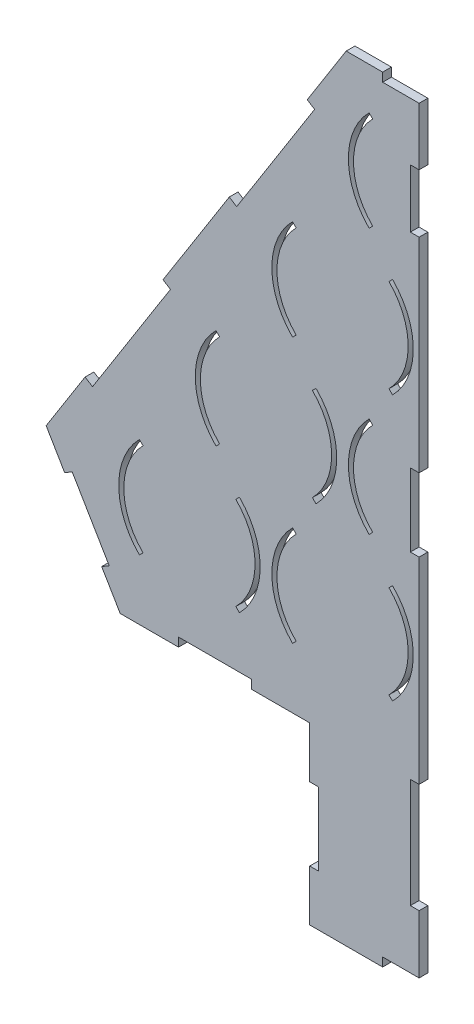
from build123d import *

# Parameters (mm, degrees)
BOSS_EXTRU_1_DEPTH      = 6
ESQUISSE2_W             = 150
ESQUISSE2_H             = 120
BOSS_EXTRU_2_DEPTH      = 6
ESQUISSE3_W             = 6
ESQUISSE3_H             = 50
ESQUISSE3_W_2           = 50
ESQUISSE3_H_2           = 6
ENL_V_MAT_EXTRU_1_DEPTH = 10
ESQUISSE4_W             = 50
ESQUISSE4_H             = 6
ENL_V_MAT_EXTRU_2_DEPTH = 10
ESQUISSE5_W             = 263.306064462
ESQUISSE5_H             = 531.54399855
ENL_V_MAT_EXTRU_5_DEPTH = 10
ESQUISSE9_W             = 6
ESQUISSE9_H             = 75
ESQUISSE9_H_2           = 50
ESQUISSE9_H_3           = 40
ENL_V_MAT_EXTRU_6_DEPTH = 10


with BuildPart() as part:
    # Esquisse1 → Boss.-Extru.1 (new body)
    with BuildSketch(Plane.XY):
        Polygon((-50, 335.901139534), (50, 335.901139534), (255.775862069, 10.507079064), (205, -75.642859016), (-205, -75.642859016), (-255.775862069, 10.507079064), align=None)
        with BuildLine():
            Line((-189.319805153, 31.819805153), (-191.794678888, 34.294678888))
            ThreePointArc((-191.794678888, 34.294678888), (-206, 0), (-191.794678888, -34.294678888))
            Line((-191.794678888, -34.294678888), (-189.319805153, -31.819805153))
            ThreePointArc((-189.319805153, -31.819805153), (-202.5, 0), (-189.319805153, 31.819805153))
        make_face(mode=Mode.SUBTRACT)
        with BuildLine():
            Line((-125.680194847, 31.819805153), (-123.205321112, 34.294678888))
            ThreePointArc((-123.205321112, 34.294678888), (-109, 0), (-123.205321112, -34.294678888))
            Line((-123.205321112, -34.294678888), (-125.680194847, -31.819805153))
            ThreePointArc((-125.680194847, -31.819805153), (-112.5, 0), (-125.680194847, 31.819805153))
        make_face(mode=Mode.SUBTRACT)
        with BuildLine():
            Line((-84.319805153, -31.819805153), (-86.794678888, -34.294678888))
            ThreePointArc((-86.794678888, -34.294678888), (-101, 0), (-86.794678888, 34.294678888))
            Line((-86.794678888, 34.294678888), (-84.319805153, 31.819805153))
            ThreePointArc((-84.319805153, 31.819805153), (-97.5, 0), (-84.319805153, -31.819805153))
        make_face(mode=Mode.SUBTRACT)
        with BuildLine():
            Line((-20.680194847, 31.819805153), (-18.205321112, 34.294678888))
            ThreePointArc((-18.205321112, 34.294678888), (-4, 0), (-18.205321112, -34.294678888))
            Line((-18.205321112, -34.294678888), (-20.680194847, -31.819805153))
            ThreePointArc((-20.680194847, -31.819805153), (-7.5, 0), (-20.680194847, 31.819805153))
        make_face(mode=Mode.SUBTRACT)
        with BuildLine():
            Line((20.680194847, -31.819805153), (18.205321112, -34.294678888))
            ThreePointArc((18.205321112, -34.294678888), (4, 0), (18.205321112, 34.294678888))
            Line((18.205321112, 34.294678888), (20.680194847, 31.819805153))
            ThreePointArc((20.680194847, 31.819805153), (7.5, 0), (20.680194847, -31.819805153))
        make_face(mode=Mode.SUBTRACT)
        with BuildLine():
            Line((84.319805153, 31.819805153), (86.794678888, 34.294678888))
            ThreePointArc((86.794678888, 34.294678888), (101, 0), (86.794678888, -34.294678888))
            Line((86.794678888, -34.294678888), (84.319805153, -31.819805153))
            ThreePointArc((84.319805153, -31.819805153), (97.5, 0), (84.319805153, 31.819805153))
        make_face(mode=Mode.SUBTRACT)
        with BuildLine():
            Line((125.680194847, -31.819805153), (123.205321112, -34.294678888))
            ThreePointArc((123.205321112, -34.294678888), (109, 0), (123.205321112, 34.294678888))
            Line((123.205321112, 34.294678888), (125.680194847, 31.819805153))
            ThreePointArc((125.680194847, 31.819805153), (112.5, 0), (125.680194847, -31.819805153))
        make_face(mode=Mode.SUBTRACT)
        with BuildLine():
            Line((189.319805153, 31.819805153), (191.794678888, 34.294678888))
            ThreePointArc((191.794678888, 34.294678888), (206, 0), (191.794678888, -34.294678888))
            Line((191.794678888, -34.294678888), (189.319805153, -31.819805153))
            ThreePointArc((189.319805153, -31.819805153), (202.5, 0), (189.319805153, 31.819805153))
        make_face(mode=Mode.SUBTRACT)
        with BuildLine():
            Line((-139.294678888, 56.63798851), (-136.819805153, 59.112862244))
            ThreePointArc((-136.819805153, 59.112862244), (-150, 90.932667397), (-136.819805153, 122.752472551))
            Line((-136.819805153, 122.752472551), (-139.294678888, 125.227346285))
            ThreePointArc((-139.294678888, 125.227346285), (-153.5, 90.932667397), (-139.294678888, 56.63798851))
        make_face(mode=Mode.SUBTRACT)
        with BuildLine():
            Line((-70.705321112, 56.63798851), (-73.180194847, 59.112862244))
            ThreePointArc((-73.180194847, 59.112862244), (-60, 90.932667397), (-73.180194847, 122.752472551))
            Line((-73.180194847, 122.752472551), (-70.705321112, 125.227346285))
            ThreePointArc((-70.705321112, 125.227346285), (-56.5, 90.932667397), (-70.705321112, 56.63798851))
        make_face(mode=Mode.SUBTRACT)
        with BuildLine():
            Line((-31.819805153, 122.752472551), (-34.294678888, 125.227346285))
            ThreePointArc((-34.294678888, 125.227346285), (-48.5, 90.932667397), (-34.294678888, 56.63798851))
            Line((-34.294678888, 56.63798851), (-31.819805153, 59.112862244))
            ThreePointArc((-31.819805153, 59.112862244), (-45, 90.932667397), (-31.819805153, 122.752472551))
        make_face(mode=Mode.SUBTRACT)
        with BuildLine():
            Line((34.294678888, 56.63798851), (31.819805153, 59.112862244))
            ThreePointArc((31.819805153, 59.112862244), (45, 90.932667397), (31.819805153, 122.752472551))
            Line((31.819805153, 122.752472551), (34.294678888, 125.227346285))
            ThreePointArc((34.294678888, 125.227346285), (48.5, 90.932667397), (34.294678888, 56.63798851))
        make_face(mode=Mode.SUBTRACT)
        with BuildLine():
            Line((73.180194847, 122.752472551), (70.705321112, 125.227346285))
            ThreePointArc((70.705321112, 125.227346285), (56.5, 90.932667397), (70.705321112, 56.63798851))
            Line((70.705321112, 56.63798851), (73.180194847, 59.112862244))
            ThreePointArc((73.180194847, 59.112862244), (60, 90.932667397), (73.180194847, 122.752472551))
        make_face(mode=Mode.SUBTRACT)
        with BuildLine():
            Line((139.294678888, 56.63798851), (136.819805153, 59.112862244))
            ThreePointArc((136.819805153, 59.112862244), (150, 90.932667397), (136.819805153, 122.752472551))
            Line((136.819805153, 122.752472551), (139.294678888, 125.227346285))
            ThreePointArc((139.294678888, 125.227346285), (153.5, 90.932667397), (139.294678888, 56.63798851))
        make_face(mode=Mode.SUBTRACT)
        with BuildLine():
            Line((-84.319805153, 213.685139948), (-86.794678888, 216.160013682))
            ThreePointArc((-86.794678888, 216.160013682), (-101, 181.865334795), (-86.794678888, 147.570655907))
            Line((-86.794678888, 147.570655907), (-84.319805153, 150.045529641))
            ThreePointArc((-84.319805153, 150.045529641), (-97.5, 181.865334795), (-84.319805153, 213.685139948))
        make_face(mode=Mode.SUBTRACT)
        with BuildLine():
            Line((-20.680194847, 213.685139948), (-18.205321112, 216.160013682))
            ThreePointArc((-18.205321112, 216.160013682), (-4, 181.865334795), (-18.205321112, 147.570655907))
            Line((-18.205321112, 147.570655907), (-20.680194847, 150.045529641))
            ThreePointArc((-20.680194847, 150.045529641), (-7.5, 181.865334795), (-20.680194847, 213.685139948))
        make_face(mode=Mode.SUBTRACT)
        with BuildLine():
            Line((20.680194847, 150.045529641), (18.205321112, 147.570655907))
            ThreePointArc((18.205321112, 147.570655907), (4, 181.865334795), (18.205321112, 216.160013682))
            Line((18.205321112, 216.160013682), (20.680194847, 213.685139948))
            ThreePointArc((20.680194847, 213.685139948), (7.5, 181.865334795), (20.680194847, 150.045529641))
        make_face(mode=Mode.SUBTRACT)
        with BuildLine():
            Line((84.319805153, 150.045529641), (86.794678888, 147.570655907))
            ThreePointArc((86.794678888, 147.570655907), (101, 181.865334795), (86.794678888, 216.160013682))
            Line((86.794678888, 216.160013682), (84.319805153, 213.685139948))
            ThreePointArc((84.319805153, 213.685139948), (97.5, 181.865334795), (84.319805153, 150.045529641))
        make_face(mode=Mode.SUBTRACT)
        with BuildLine():
            Line((-31.819805153, 304.617807345), (-34.294678888, 307.09268108))
            ThreePointArc((-34.294678888, 307.09268108), (-48.5, 272.798002192), (-34.294678888, 238.503323305))
            Line((-34.294678888, 238.503323305), (-31.819805153, 240.978197039))
            ThreePointArc((-31.819805153, 240.978197039), (-45, 272.798002192), (-31.819805153, 304.617807345))
        make_face(mode=Mode.SUBTRACT)
        with BuildLine():
            Line((31.819805153, 304.617807345), (34.294678888, 307.09268108))
            ThreePointArc((34.294678888, 307.09268108), (48.5, 272.798002192), (34.294678888, 238.503323305))
            Line((34.294678888, 238.503323305), (31.819805153, 240.978197039))
            ThreePointArc((31.819805153, 240.978197039), (45, 272.798002192), (31.819805153, 304.617807345))
        make_face(mode=Mode.SUBTRACT)
    extrude(amount=BOSS_EXTRU_1_DEPTH)

    # Esquisse2 → Boss.-Extru.2 (add)
    with BuildSketch(Plane.XY.offset(6)):
        with Locations((0, -135.642859016)):
            Rectangle(ESQUISSE2_W, ESQUISSE2_H)
    extrude(amount=-BOSS_EXTRU_2_DEPTH)

    # Esquisse3 → Enlèv. mat.-Extru.1 (cut)
    with BuildSketch(Plane.XY.offset(6)):
        with Locations((-72, -135.642859016)):
            Rectangle(ESQUISSE3_W, ESQUISSE3_H)
        with Locations((0, -192.642859016)):
            Rectangle(ESQUISSE3_W_2, ESQUISSE3_H_2)
        with Locations((72, -135.642859016)):
            Rectangle(ESQUISSE3_W, ESQUISSE3_H)
    extrude(amount=-ENL_V_MAT_EXTRU_1_DEPTH, mode=Mode.SUBTRACT)

    # Esquisse4 → Enlèv. mat.-Extru.2 (cut)
    with BuildSketch(Plane.XY.offset(6)):
        with Locations((-140, -72.642859016)):
            Rectangle(ESQUISSE4_W, ESQUISSE4_H)
        Polygon((-217.693965517, -54.105374496), (-212.524969232, -51.058822772), (-237.912900267, -7.983853732), (-243.081896552, -11.030405456), align=None)
        Polygon((-229.051724138, 52.766047956), (-223.980647871, 49.559151404), (-170.532372009, 134.077089189), (-175.603448276, 137.283985741), align=None)
        Polygon((-71.653061664, 290.43527409), (-76.724137931, 293.642170642), (-130.172413793, 209.124232857), (-125.101337526, 205.917336306), align=None)
        with Locations((0, 332.901139534)):
            Rectangle(ESQUISSE4_W, ESQUISSE4_H)
        with Locations((140, -72.642859016)):
            Rectangle(ESQUISSE4_W, ESQUISSE4_H)
        Polygon((237.912900267, -7.983853732), (243.081896552, -11.030405456), (217.693965517, -54.105374496), (212.524969232, -51.058822772), align=None)
        Polygon((170.532372009, 134.077089189), (175.603448276, 137.283985741), (229.051724138, 52.766047956), (223.980647871, 49.559151404), align=None)
        Polygon((125.101337526, 205.917336306), (130.172413793, 209.124232857), (76.724137931, 293.642170642), (71.653061664, 290.43527409), align=None)
    extrude(amount=-ENL_V_MAT_EXTRU_2_DEPTH, mode=Mode.SUBTRACT)

    # Esquisse5 → Enlèv. mat.-Extru.5 (cut)
    with BuildSketch(Plane.XY.offset(6)):
        with Locations((131.653032231, 70.129140259)):
            Rectangle(ESQUISSE5_W, ESQUISSE5_H)
    extrude(amount=-ENL_V_MAT_EXTRU_5_DEPTH, mode=Mode.SUBTRACT)

    # Esquisse9 → Enlèv. mat.-Extru.6 (cut)
    with BuildSketch(Plane.XY.offset(6)):
        with Locations((-3, -112.142859016)):
            Rectangle(ESQUISSE9_W, ESQUISSE9_H)
        with Locations((-3, 85.357140984)):
            Rectangle(ESQUISSE9_W, ESQUISSE9_H_2)
        with Locations((-3, 270.357140984)):
            Rectangle(ESQUISSE9_W, ESQUISSE9_H_3)
    extrude(amount=-ENL_V_MAT_EXTRU_6_DEPTH, mode=Mode.SUBTRACT)


solid = part.part
